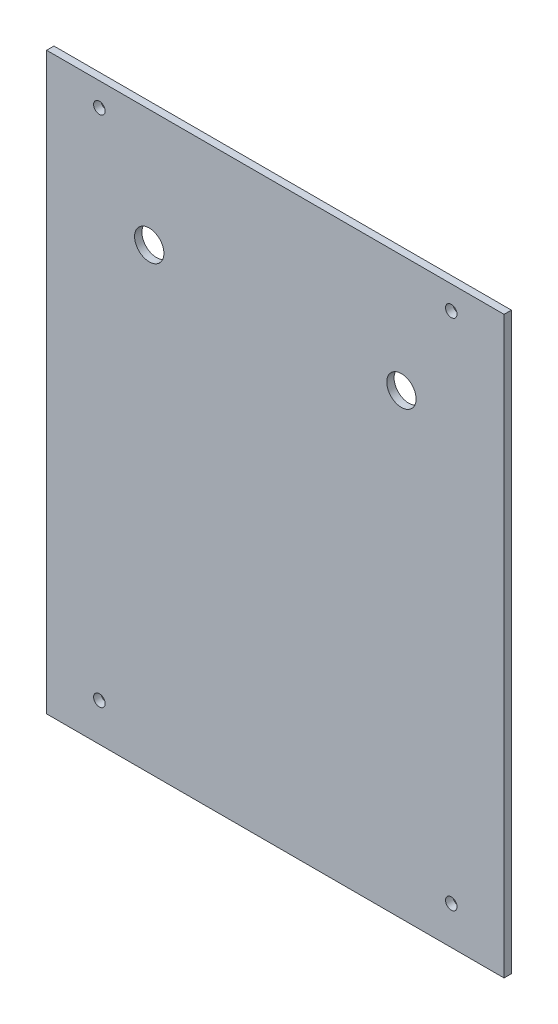
from build123d import *

# Parameters (mm, degrees)
SKETCH1_W           = 198.12
SKETCH1_H           = 248.92
SKETCH1_R           = 2.5
BOSS_EXTRUDE1_DEPTH = 3.175
SKETCH2_R           = 6.35
CUT_EXTRUDE1_DEPTH  = 4.175


with BuildPart() as part:
    # Sketch1 → Boss-Extrude1 (new body)
    with BuildSketch(Plane.XY):
        with Locations((0, -152.4)):
            Rectangle(SKETCH1_W, SKETCH1_H)
        with Locations((-76.2, -260.35)):
            Circle(SKETCH1_R, mode=Mode.SUBTRACT)
        with Locations((-76.2, -38.1)):
            Circle(SKETCH1_R, mode=Mode.SUBTRACT)
        with Locations((76.2, -38.1)):
            Circle(SKETCH1_R, mode=Mode.SUBTRACT)
        with Locations((76.2, -260.35)):
            Circle(SKETCH1_R, mode=Mode.SUBTRACT)
    extrude(amount=BOSS_EXTRUDE1_DEPTH)

    # Sketch2 → Cut-Extrude1 (cut, through all)
    with BuildSketch(Plane.XY.offset(3.175)):
        with Locations((-54.61, -78.74)):
            Circle(SKETCH2_R)
        with Locations((54.61, -78.74)):
            Circle(SKETCH2_R)
    extrude(amount=-CUT_EXTRUDE1_DEPTH, mode=Mode.SUBTRACT)


solid = part.part
